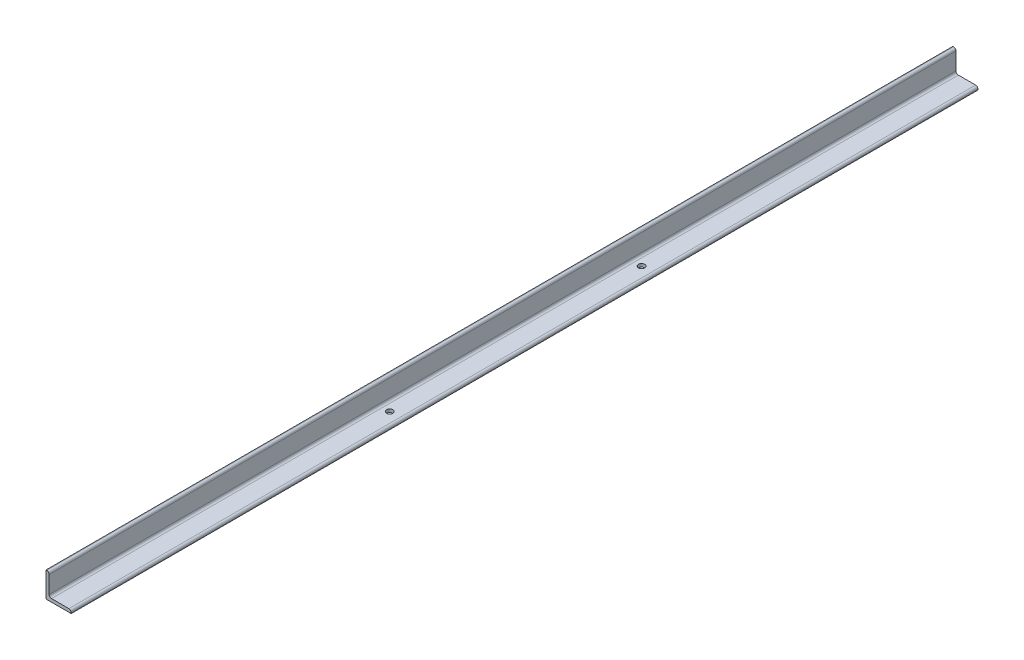
from build123d import *

# Parameters (mm, degrees)
BOSS_EXTRUDE1_DEPTH = 914.4
CUT_EXTRUDE2_REACH  = 52.8
SKETCH5_R           = 6.35


with BuildPart() as part:
    # Sketch1 → Boss-Extrude1 (new body, symmetric)
    with BuildSketch(Plane.XY):
        with BuildLine():
            Line((0, 0), (0, 50.8))
            Line((0, 50.8), (1.59258, 50.8))
            ThreePointArc((1.59258, 50.8), (4.956583943, 49.406583943), (6.35, 46.04258))
            Line((6.35, 46.04258), (6.35, 11.1125))
            ThreePointArc((6.35, 11.1125), (7.744903955, 7.744903955), (11.1125, 6.35))
            Line((11.1125, 6.35), (46.04258, 6.35))
            ThreePointArc((46.04258, 6.35), (49.406583943, 4.956583943), (50.8, 1.59258))
            Line((50.8, 1.59258), (50.8, 0))
            Line((50.8, 0), (0, 0))
        make_face()
    extrude(amount=BOSS_EXTRUDE1_DEPTH, both=True)

    # Sketch5 → Cut-Extrude2 (cut, up to next)
    with BuildSketch(Plane.XZ, mode=Mode.PRIVATE) as cut_extrude2_sk1:
        with Locations((25.4, -261.366)):
            Circle(SKETCH5_R)
    cut_extrude2_tool1 = extrude(cut_extrude2_sk1.sketch, amount=-CUT_EXTRUDE2_REACH, mode=Mode.PRIVATE) & part.part
    add(cut_extrude2_tool1.solids().sort_by_distance((25.4, 0, -261.366))[0], mode=Mode.SUBTRACT)
    # Sketch5 → Cut-Extrude2 (cut, up to next)
    with BuildSketch(Plane.XZ, mode=Mode.PRIVATE) as cut_extrude2_sk2:
        with Locations((25.4, 246.634)):
            Circle(SKETCH5_R)
    cut_extrude2_tool2 = extrude(cut_extrude2_sk2.sketch, amount=-CUT_EXTRUDE2_REACH, mode=Mode.PRIVATE) & part.part
    add(cut_extrude2_tool2.solids().sort_by_distance((25.4, 0, 246.634))[0], mode=Mode.SUBTRACT)


solid = part.part
